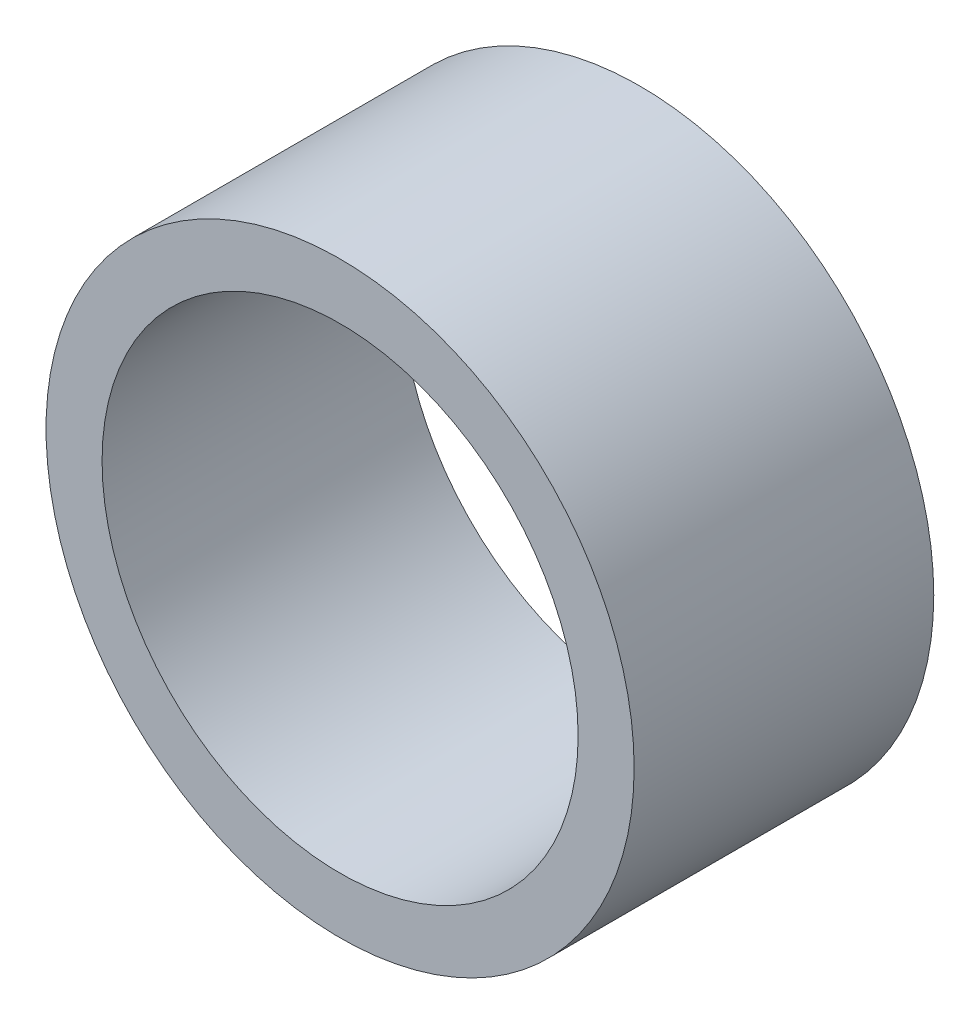
from build123d import *

# Parameters (mm, degrees)
SKIZZE1_R                       = 10.5
SKIZZE1_R_2                     = 8.5
AUFSATZ_LINEAR_AUSTRAGEN1_DEPTH = 10.7


with BuildPart() as part:
    # Skizze1 → Aufsatz-Linear austragen1 (new body)
    with BuildSketch(Plane.XY):
        Circle(SKIZZE1_R)
        Circle(SKIZZE1_R_2, mode=Mode.SUBTRACT)
    extrude(amount=AUFSATZ_LINEAR_AUSTRAGEN1_DEPTH)


solid = part.part
